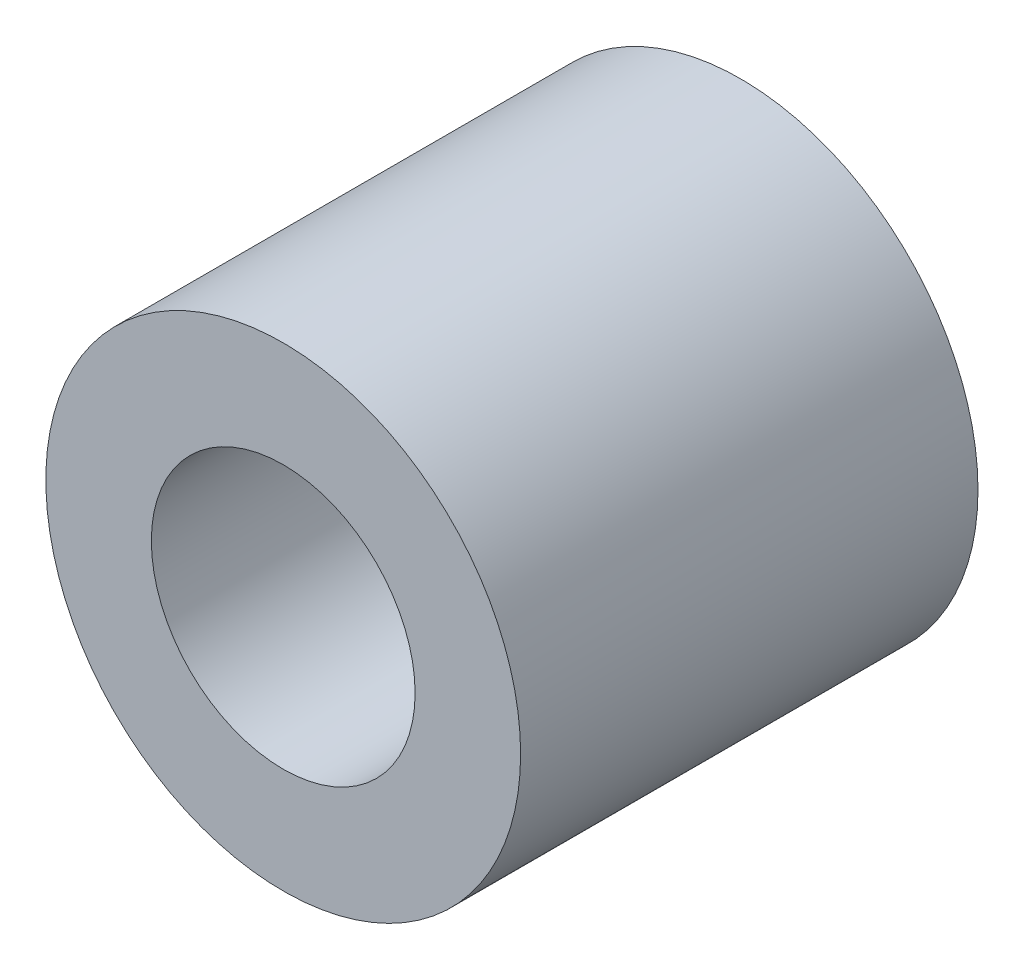
from build123d import *

# Parameters (mm, degrees)
SKETCH1_R           = 4.5
SKETCH1_R_2         = 2.5
BOSS_EXTRUDE1_DEPTH = 8.67


with BuildPart() as part:
    # Sketch1 → Boss-Extrude1 (new body)
    with BuildSketch(Plane.XY):
        Circle(SKETCH1_R)
        Circle(SKETCH1_R_2, mode=Mode.SUBTRACT)
    extrude(amount=BOSS_EXTRUDE1_DEPTH)


solid = part.part
